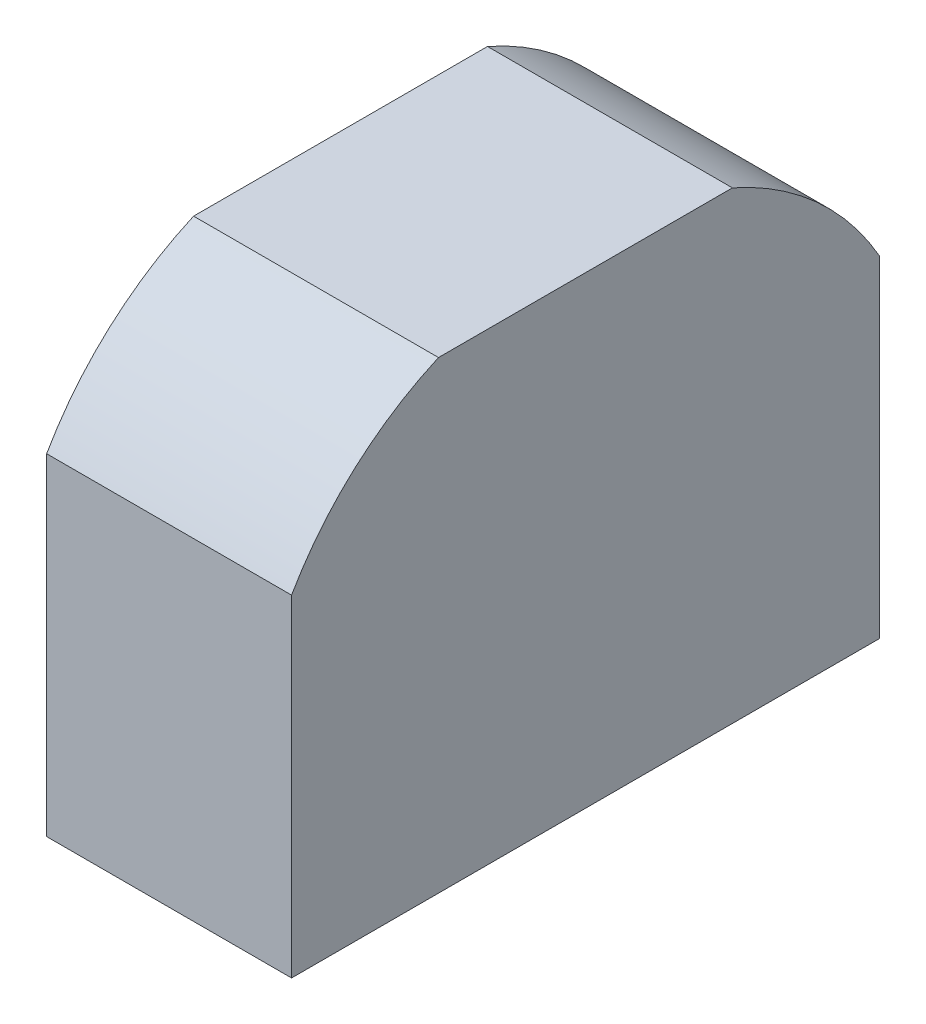
from build123d import *

# Parameters (mm, degrees)
BOSS_EXTRUDE1_DEPTH      = 15
BOSS_EXTRUDE1_DEPTH_BACK = 15
SKETCH2_R                = 2.45
BOSS_EXTRUDE2_DEPTH      = 5
CUT_EXTRUDE1_DEPTH       = 114.633181774
BOSS_EXTRUDE3_DEPTH      = 25
SKETCH5_W                = 5.325066076
SKETCH5_H                = 5.499463709
CUT_EXTRUDE2_DEPTH       = 3
SKETCH6_W                = 135.823798811
SKETCH6_H                = 59.856144922
CUT_EXTRUDE3_DEPTH       = 119.47995628
SKETCH7_W                = 30
SKETCH7_H                = 30.150652204
CUT_EXTRUDE6_DEPTH       = 162.822831918


with BuildPart() as part:
    # Sketch1 → Boss-Extrude1 (new, two sides: drawn at the far end of the back side and taken through both)
    with BuildSketch(Plane.XY.offset(-BOSS_EXTRUDE1_DEPTH_BACK)):
        with BuildLine():
            Line((-77.5, 0), (77.5, 0))
            ThreePointArc((77.5, 0), (0, 77.5), (-77.5, 0))
        make_face()
    extrude(amount=BOSS_EXTRUDE1_DEPTH + BOSS_EXTRUDE1_DEPTH_BACK)

    # Sketch2 → Boss-Extrude2 (add)
    with BuildSketch(Plane.XZ):
        with Locations((67.5, 10)):
            Circle(SKETCH2_R)
        with Locations((67.5, -10)):
            Circle(SKETCH2_R)
        with Locations((-67.5, -10)):
            Circle(SKETCH2_R)
        with Locations((-67.5, 10)):
            Circle(SKETCH2_R)
    extrude(amount=BOSS_EXTRUDE2_DEPTH)

    # Sketch3 → Cut-Extrude1 (cut, through all)
    with BuildSketch(Plane.XY.offset(15)):
        with BuildLine():
            Line((-53.909646632, 20), (53.909646632, 20))
            ThreePointArc((53.909646632, 20), (0, -57.5), (-53.909646632, 20))
        make_face()
    extrude(amount=-CUT_EXTRUDE1_DEPTH, mode=Mode.SUBTRACT)

    # Sketch4 → Boss-Extrude3 (add)
    with BuildSketch(Plane(origin=(-77.5, 0, 0), x_dir=(0, 0, -1), z_dir=(1, 0, 0))):
        with BuildLine():
            Line((-30, 0), (30, 0))
            Line((30, 0), (30, 33.846717608))
            ThreePointArc((30, 33.846717608), (17.313763728, 46.220498553), (0, 50))
            ThreePointArc((0, 50), (-17.313763728, 46.220498553), (-30, 33.846717608))
            Line((-30, 33.846717608), (-30, 0))
        make_face()
    extrude(amount=BOSS_EXTRUDE3_DEPTH)

    # Sketch5 → Cut-Extrude2 (cut)
    with BuildSketch(Plane.ZY.offset(77.5)):
        Polygon((19.368451097, 32.27320265), (6.086727423, 27.500083204), (6.086727423, 20.23664057), (19.368451097, 20.23664057), align=None)
        with BuildLine():
            ThreePointArc((-9.459040074, 11.728036341), (-11.621010767, 10.517694382), (-12.831352726, 8.35572369))
            Line((-12.831352726, 8.35572369), (-12.831352726, 6.228572632))
            Line((-12.831352726, 6.228572632), (-6.086727423, 6.228572632))
            Line((-6.086727423, 6.228572632), (-6.086727423, 11.728036341))
            Line((-6.086727423, 11.728036341), (-9.459040074, 11.728036341))
        make_face()
        with Locations((0, 8.978304487)):
            Rectangle(SKETCH5_W, SKETCH5_H)
        with BuildLine():
            Line((9.459040074, 11.728036341), (6.086727423, 11.728036341))
            Line((6.086727423, 11.728036341), (6.086727423, 6.228572632))
            Line((6.086727423, 6.228572632), (12.831352726, 6.228572632))
            Line((12.831352726, 6.228572632), (12.831352726, 8.35572369))
            ThreePointArc((12.831352726, 8.35572369), (11.621010767, 10.517694382), (9.459040074, 11.728036341))
        make_face()
        Polygon((-19.368451097, 20.23664057), (-6.086727423, 20.23664057), (-6.086727423, 27.500083204), (-19.368451097, 32.27320265), align=None)
    extrude(amount=-CUT_EXTRUDE2_DEPTH, mode=Mode.SUBTRACT)

    # Sketch6 → Cut-Extrude3 (cut, through all)
    with BuildSketch(Plane.XY.offset(15)):
        with Locations((15.411899406, 17.421275335)):
            Rectangle(SKETCH6_W, SKETCH6_H)
    extrude(amount=-CUT_EXTRUDE3_DEPTH, mode=Mode.SUBTRACT)

    # Sketch7 → Cut-Extrude6 (cut, through all)
    with BuildSketch(Plane(origin=(-77.5, 0, 0), x_dir=(0, 0, -1), z_dir=(1, 0, 0))):
        with Locations((0, 62.424673898)):
            Rectangle(SKETCH7_W, SKETCH7_H)
    extrude(amount=CUT_EXTRUDE6_DEPTH, mode=Mode.SUBTRACT)


solid = part.part
